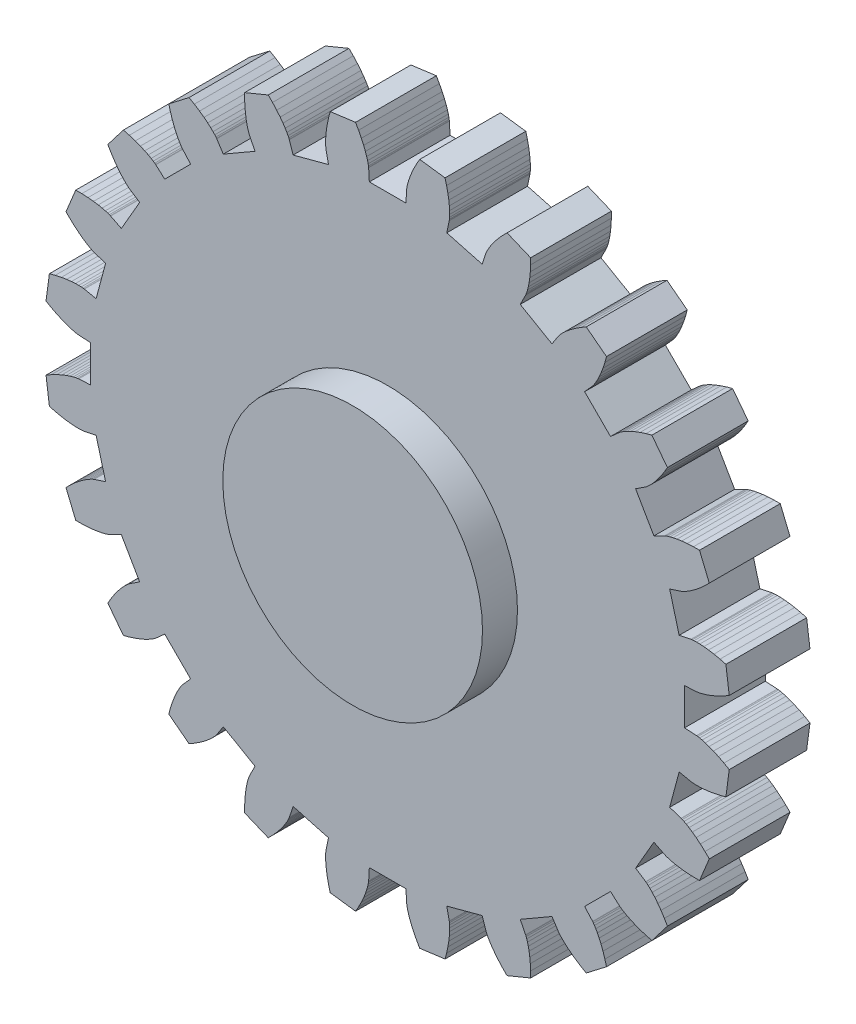
from build123d import *

# Parameters (mm, degrees)
MAIN_GEAR_BODY_DEPTH         = 3
SKETCH2_R                    = 5
CENTRAL_FEATURE_DEPTH        = 1.3
CENTRAL_FEATURE_DEPTH_BACK   = 4.3
SKETCH3_OUTSIDE_W            = 34.792
SKETCH3_OUTSIDE_H            = 34.792
TEETH_CLEARANCE_DEPTH        = 5.3
SKETCH4_R                    = 5
SKETCH4_R_2                  = 4.825
PRINT_CLEARANCE_TOP_DEPTH    = 1.3
SKETCH6_R                    = 5
SKETCH6_R_2                  = 4.825
PRINT_CLEARANCE_BOTTOM_DEPTH = 1.3


with BuildPart() as part:
    # Model → Main Gear Body (new body)
    with BuildSketch(Plane.XY):
        Polygon((11.481280763, -0.655890262), (11.081931867, -0.633076687), (11.081931867, 0.633076687), (11.481280763, 0.655890262), (11.494959484, 0.657119822), (11.535795525, 0.662587053), (11.603342457, 0.674939875), (11.696960474, 0.69678954), (11.81581907, 0.730698092), (11.958900465, 0.779166001), (12.125003794, 0.844620031), (12.312750022, 0.929401369), (12.520587586, 1.035754071), (12.746798737, 1.165813859), (12.614196933, 2.173024562), (12.36203179, 2.240104916), (12.133750013, 2.289041418), (11.930458058, 2.322341602), (11.753073814, 2.342574636), (11.602323381, 2.352358851), (11.478738615, 2.354349128), (11.382655444, 2.351224158), (11.314212973, 2.345673635), (11.273353363, 2.34038543), (11.259822499, 2.338032781), (10.868176499, 2.256709902), (10.540471892, 3.479720146), (10.920308717, 3.605115467), (10.933203113, 3.609843444), (10.971232676, 3.625693529), (11.033280856, 3.655107871), (11.118053808, 3.700443153), (11.224086216, 3.763959167), (11.349747813, 3.847807762), (11.493250558, 3.954022205), (11.652656464, 4.084506989), (11.82588603, 4.24102813), (12.010727273, 4.425203993), (11.621958453, 5.36377495), (11.361023956, 5.363304455), (11.127854994, 5.351489815), (10.922871322, 5.331039494), (10.746294605, 5.304672682), (10.598148527, 5.275106425), (10.478259688, 5.245042794), (10.386259274, 5.21715615), (10.321585504, 5.194080542), (10.28348684, 5.178397283), (10.27102594, 5.172622753), (9.913772864, 4.99270544), (9.280696176, 6.089226427), (9.615135678, 6.30865801), (9.626367017, 6.316562201), (9.658998451, 6.341714983), (9.711319399, 6.386186306), (9.781470148, 6.45191768), (9.867450435, 6.540712645), (9.967128604, 6.654227783), (10.078251291, 6.7939643), (10.198453625, 6.961260207), (10.325269884, 7.157283131), (10.456144594, 7.383023787), (9.837702711, 8.18899294), (9.585781114, 8.121003659), (9.363615046, 8.049243025), (9.170908956, 7.976435853), (9.007173178, 7.905266052), (8.871727365, 7.838364214), (8.76370468, 7.778295462), (8.682056698, 7.727547573), (8.625559041, 7.688519444), (8.592817683, 7.663509918), (8.582275936, 7.654707033), (8.28376199, 7.388456353), (7.388456353, 8.28376199), (7.654707033, 8.582275936), (7.663509918, 8.592817683), (7.688519444, 8.625559041), (7.727547573, 8.682056698), (7.778295462, 8.76370468), (7.838364214, 8.871727365), (7.905266052, 9.007173178), (7.976435853, 9.170908956), (8.049243025, 9.363615046), (8.121003659, 9.585781114), (8.18899294, 9.837702711), (7.383023787, 10.456144594), (7.157283131, 10.325269884), (6.961260207, 10.198453625), (6.7939643, 10.078251291), (6.654227783, 9.967128604), (6.540712645, 9.867450435), (6.45191768, 9.781470148), (6.386186306, 9.711319399), (6.341714983, 9.658998451), (6.316562201, 9.626367017), (6.30865801, 9.615135678), (6.089226427, 9.280696176), (4.99270544, 9.913772864), (5.172622753, 10.27102594), (5.178397283, 10.28348684), (5.194080542, 10.321585504), (5.21715615, 10.386259274), (5.245042794, 10.478259688), (5.275106425, 10.598148527), (5.304672682, 10.746294605), (5.331039494, 10.922871322), (5.351489815, 11.127854994), (5.363304455, 11.361023956), (5.36377495, 11.621958453), (4.425203993, 12.010727273), (4.24102813, 11.82588603), (4.084506989, 11.652656464), (3.954022205, 11.493250558), (3.847807762, 11.349747813), (3.763959167, 11.224086216), (3.700443153, 11.118053808), (3.655107871, 11.033280856), (3.625693529, 10.971232676), (3.609843444, 10.933203113), (3.605115467, 10.920308717), (3.479720146, 10.540471892), (2.256709902, 10.868176499), (2.338032781, 11.259822499), (2.34038543, 11.273353363), (2.345673635, 11.314212973), (2.351224158, 11.382655444), (2.354349128, 11.478738615), (2.352358851, 11.602323381), (2.342574636, 11.753073814), (2.322341602, 11.930458058), (2.289041418, 12.133750013), (2.240104916, 12.36203179), (2.173024562, 12.614196933), (1.165813859, 12.746798737), (1.035754071, 12.520587586), (0.929401369, 12.312750022), (0.844620031, 12.125003794), (0.779166001, 11.958900465), (0.730698092, 11.81581907), (0.69678954, 11.696960474), (0.674939875, 11.603342457), (0.662587053, 11.535795525), (0.657119822, 11.494959484), (0.655890262, 11.481280763), (0.633076687, 11.081931867), (-0.633076687, 11.081931867), (-0.655890262, 11.481280763), (-0.657119822, 11.494959484), (-0.662587053, 11.535795525), (-0.674939875, 11.603342457), (-0.69678954, 11.696960474), (-0.730698092, 11.81581907), (-0.779166001, 11.958900465), (-0.844620031, 12.125003794), (-0.929401369, 12.312750022), (-1.035754071, 12.520587586), (-1.165813859, 12.746798737), (-2.173024562, 12.614196933), (-2.240104916, 12.36203179), (-2.289041418, 12.133750013), (-2.322341602, 11.930458058), (-2.342574636, 11.753073814), (-2.352358851, 11.602323381), (-2.354349128, 11.478738615), (-2.351224158, 11.382655444), (-2.345673635, 11.314212973), (-2.34038543, 11.273353363), (-2.338032781, 11.259822499), (-2.256709902, 10.868176499), (-3.479720146, 10.540471892), (-3.605115467, 10.920308717), (-3.609843444, 10.933203113), (-3.625693529, 10.971232676), (-3.655107871, 11.033280856), (-3.700443153, 11.118053808), (-3.763959167, 11.224086216), (-3.847807762, 11.349747813), (-3.954022205, 11.493250558), (-4.084506989, 11.652656464), (-4.24102813, 11.82588603), (-4.425203993, 12.010727273), (-5.36377495, 11.621958453), (-5.363304455, 11.361023956), (-5.351489815, 11.127854994), (-5.331039494, 10.922871322), (-5.304672682, 10.746294605), (-5.275106425, 10.598148527), (-5.245042794, 10.478259688), (-5.21715615, 10.386259274), (-5.194080542, 10.321585504), (-5.178397283, 10.28348684), (-5.172622753, 10.27102594), (-4.99270544, 9.913772864), (-6.089226427, 9.280696176), (-6.30865801, 9.615135678), (-6.316562201, 9.626367017), (-6.341714983, 9.658998451), (-6.386186306, 9.711319399), (-6.45191768, 9.781470148), (-6.540712645, 9.867450435), (-6.654227783, 9.967128604), (-6.7939643, 10.078251291), (-6.961260207, 10.198453625), (-7.157283131, 10.325269884), (-7.383023787, 10.456144594), (-8.18899294, 9.837702711), (-8.121003659, 9.585781114), (-8.049243025, 9.363615046), (-7.976435853, 9.170908956), (-7.905266052, 9.007173178), (-7.838364214, 8.871727365), (-7.778295462, 8.76370468), (-7.727547573, 8.682056698), (-7.688519444, 8.625559041), (-7.663509918, 8.592817683), (-7.654707033, 8.582275936), (-7.388456353, 8.28376199), (-8.28376199, 7.388456353), (-8.582275936, 7.654707033), (-8.592817683, 7.663509918), (-8.625559041, 7.688519444), (-8.682056698, 7.727547573), (-8.76370468, 7.778295462), (-8.871727365, 7.838364214), (-9.007173178, 7.905266052), (-9.170908956, 7.976435853), (-9.363615046, 8.049243025), (-9.585781114, 8.121003659), (-9.837702711, 8.18899294), (-10.456144594, 7.383023787), (-10.325269884, 7.157283131), (-10.198453625, 6.961260207), (-10.078251291, 6.7939643), (-9.967128604, 6.654227783), (-9.867450435, 6.540712645), (-9.781470148, 6.45191768), (-9.711319399, 6.386186306), (-9.658998451, 6.341714983), (-9.626367017, 6.316562201), (-9.615135678, 6.30865801), (-9.280696176, 6.089226427), (-9.913772864, 4.99270544), (-10.27102594, 5.172622753), (-10.28348684, 5.178397283), (-10.321585504, 5.194080542), (-10.386259274, 5.21715615), (-10.478259688, 5.245042794), (-10.598148527, 5.275106425), (-10.746294605, 5.304672682), (-10.922871322, 5.331039494), (-11.127854994, 5.351489815), (-11.361023956, 5.363304455), (-11.621958453, 5.36377495), (-12.010727273, 4.425203993), (-11.82588603, 4.24102813), (-11.652656464, 4.084506989), (-11.493250558, 3.954022205), (-11.349747813, 3.847807762), (-11.224086216, 3.763959167), (-11.118053808, 3.700443153), (-11.033280856, 3.655107871), (-10.971232676, 3.625693529), (-10.933203113, 3.609843444), (-10.920308717, 3.605115467), (-10.540471892, 3.479720146), (-10.868176499, 2.256709902), (-11.259822499, 2.338032781), (-11.273353363, 2.34038543), (-11.314212973, 2.345673635), (-11.382655444, 2.351224158), (-11.478738615, 2.354349128), (-11.602323381, 2.352358851), (-11.753073814, 2.342574636), (-11.930458058, 2.322341602), (-12.133750014, 2.289041418), (-12.36203179, 2.240104916), (-12.614196933, 2.173024562), (-12.746798737, 1.165813859), (-12.520587586, 1.035754071), (-12.312750022, 0.929401369), (-12.125003794, 0.844620031), (-11.958900465, 0.779166001), (-11.81581907, 0.730698092), (-11.696960474, 0.69678954), (-11.603342457, 0.674939875), (-11.535795525, 0.662587053), (-11.494959484, 0.657119822), (-11.481280763, 0.655890262), (-11.081931867, 0.633076687), (-11.081931867, -0.633076687), (-11.481280763, -0.655890262), (-11.494959484, -0.657119822), (-11.535795525, -0.662587053), (-11.603342457, -0.674939875), (-11.696960474, -0.69678954), (-11.81581907, -0.730698092), (-11.958900465, -0.779166001), (-12.125003794, -0.844620031), (-12.312750022, -0.929401369), (-12.520587586, -1.035754071), (-12.746798737, -1.165813859), (-12.614196933, -2.173024562), (-12.36203179, -2.240104916), (-12.133750014, -2.289041418), (-11.930458058, -2.322341602), (-11.753073814, -2.342574636), (-11.602323381, -2.352358851), (-11.478738615, -2.354349128), (-11.382655444, -2.351224158), (-11.314212973, -2.345673635), (-11.273353363, -2.34038543), (-11.259822499, -2.338032781), (-10.868176499, -2.256709902), (-10.540471892, -3.479720146), (-10.920308717, -3.605115467), (-10.933203113, -3.609843444), (-10.971232676, -3.625693529), (-11.033280856, -3.655107871), (-11.118053808, -3.700443153), (-11.224086216, -3.763959167), (-11.349747813, -3.847807762), (-11.493250558, -3.954022205), (-11.652656464, -4.084506989), (-11.82588603, -4.24102813), (-12.010727273, -4.425203993), (-11.621958453, -5.36377495), (-11.361023956, -5.363304455), (-11.127854994, -5.351489815), (-10.922871322, -5.331039494), (-10.746294605, -5.304672682), (-10.598148527, -5.275106425), (-10.478259688, -5.245042794), (-10.386259274, -5.21715615), (-10.321585504, -5.194080542), (-10.28348684, -5.178397283), (-10.27102594, -5.172622753), (-9.913772864, -4.99270544), (-9.280696176, -6.089226427), (-9.615135678, -6.30865801), (-9.626367017, -6.316562201), (-9.658998451, -6.341714983), (-9.711319399, -6.386186306), (-9.781470148, -6.45191768), (-9.867450435, -6.540712645), (-9.967128604, -6.654227783), (-10.078251291, -6.7939643), (-10.198453625, -6.961260207), (-10.325269884, -7.157283131), (-10.456144594, -7.383023787), (-9.837702711, -8.18899294), (-9.585781114, -8.121003659), (-9.363615046, -8.049243025), (-9.170908956, -7.976435853), (-9.007173178, -7.905266052), (-8.871727365, -7.838364214), (-8.76370468, -7.778295462), (-8.682056698, -7.727547573), (-8.625559041, -7.688519444), (-8.592817683, -7.663509918), (-8.582275936, -7.654707033), (-8.28376199, -7.388456353), (-7.388456353, -8.28376199), (-7.654707033, -8.582275936), (-7.663509918, -8.592817683), (-7.688519444, -8.625559041), (-7.727547573, -8.682056698), (-7.778295462, -8.76370468), (-7.838364214, -8.871727365), (-7.905266052, -9.007173178), (-7.976435853, -9.170908956), (-8.049243025, -9.363615046), (-8.121003659, -9.585781114), (-8.18899294, -9.837702711), (-7.383023787, -10.456144594), (-7.157283131, -10.325269884), (-6.961260207, -10.198453625), (-6.7939643, -10.078251291), (-6.654227783, -9.967128604), (-6.540712645, -9.867450435), (-6.45191768, -9.781470148), (-6.386186306, -9.711319399), (-6.341714983, -9.658998451), (-6.316562201, -9.626367017), (-6.30865801, -9.615135678), (-6.089226427, -9.280696176), (-4.99270544, -9.913772864), (-5.172622753, -10.27102594), (-5.178397283, -10.28348684), (-5.194080542, -10.321585504), (-5.21715615, -10.386259274), (-5.245042794, -10.478259688), (-5.275106425, -10.598148527), (-5.304672682, -10.746294605), (-5.331039494, -10.922871322), (-5.351489815, -11.127854994), (-5.363304455, -11.361023956), (-5.36377495, -11.621958453), (-4.425203993, -12.010727273), (-4.24102813, -11.82588603), (-4.084506989, -11.652656464), (-3.954022205, -11.493250558), (-3.847807762, -11.349747813), (-3.763959167, -11.224086216), (-3.700443153, -11.118053808), (-3.655107871, -11.033280856), (-3.625693529, -10.971232676), (-3.609843444, -10.933203113), (-3.605115467, -10.920308717), (-3.479720146, -10.540471892), (-2.256709902, -10.868176499), (-2.338032781, -11.259822499), (-2.34038543, -11.273353363), (-2.345673635, -11.314212973), (-2.351224158, -11.382655444), (-2.354349128, -11.478738615), (-2.352358851, -11.602323381), (-2.342574636, -11.753073814), (-2.322341602, -11.930458058), (-2.289041418, -12.133750013), (-2.240104916, -12.36203179), (-2.173024562, -12.614196933), (-1.165813859, -12.746798737), (-1.035754071, -12.520587586), (-0.929401369, -12.312750022), (-0.844620031, -12.125003794), (-0.779166001, -11.958900465), (-0.730698092, -11.81581907), (-0.69678954, -11.696960474), (-0.674939875, -11.603342457), (-0.662587053, -11.535795525), (-0.657119822, -11.494959484), (-0.655890262, -11.481280763), (-0.633076687, -11.081931867), (0.633076687, -11.081931867), (0.655890262, -11.481280763), (0.657119822, -11.494959484), (0.662587053, -11.535795525), (0.674939875, -11.603342457), (0.69678954, -11.696960474), (0.730698092, -11.81581907), (0.779166001, -11.958900465), (0.844620031, -12.125003794), (0.929401369, -12.312750022), (1.035754071, -12.520587586), (1.165813859, -12.746798737), (2.173024562, -12.614196933), (2.240104916, -12.36203179), (2.289041418, -12.133750013), (2.322341602, -11.930458058), (2.342574636, -11.753073814), (2.352358851, -11.602323381), (2.354349128, -11.478738615), (2.351224158, -11.382655444), (2.345673635, -11.314212973), (2.34038543, -11.273353363), (2.338032781, -11.259822499), (2.256709902, -10.868176499), (3.479720146, -10.540471892), (3.605115467, -10.920308717), (3.609843444, -10.933203113), (3.625693529, -10.971232676), (3.655107871, -11.033280856), (3.700443153, -11.118053808), (3.763959167, -11.224086216), (3.847807762, -11.349747813), (3.954022205, -11.493250558), (4.084506989, -11.652656464), (4.24102813, -11.82588603), (4.425203993, -12.010727273), (5.36377495, -11.621958453), (5.363304455, -11.361023956), (5.351489815, -11.127854994), (5.331039494, -10.922871322), (5.304672682, -10.746294605), (5.275106425, -10.598148527), (5.245042794, -10.478259688), (5.21715615, -10.386259274), (5.194080542, -10.321585504), (5.178397283, -10.28348684), (5.172622753, -10.27102594), (4.99270544, -9.913772864), (6.089226427, -9.280696176), (6.30865801, -9.615135678), (6.316562201, -9.626367017), (6.341714983, -9.658998451), (6.386186306, -9.711319399), (6.45191768, -9.781470148), (6.540712645, -9.867450435), (6.654227783, -9.967128604), (6.7939643, -10.078251291), (6.961260207, -10.198453625), (7.157283131, -10.325269884), (7.383023787, -10.456144594), (8.18899294, -9.837702711), (8.121003659, -9.585781114), (8.049243025, -9.363615046), (7.976435853, -9.170908956), (7.905266052, -9.007173178), (7.838364214, -8.871727365), (7.778295462, -8.76370468), (7.727547573, -8.682056698), (7.688519444, -8.625559041), (7.663509918, -8.592817683), (7.654707033, -8.582275936), (7.388456353, -8.28376199), (8.28376199, -7.388456353), (8.582275936, -7.654707033), (8.592817683, -7.663509918), (8.625559041, -7.688519444), (8.682056698, -7.727547573), (8.76370468, -7.778295462), (8.871727365, -7.838364214), (9.007173178, -7.905266052), (9.170908956, -7.976435853), (9.363615046, -8.049243025), (9.585781114, -8.121003659), (9.837702711, -8.18899294), (10.456144594, -7.383023787), (10.325269884, -7.157283131), (10.198453625, -6.961260207), (10.078251291, -6.7939643), (9.967128604, -6.654227783), (9.867450435, -6.540712645), (9.781470148, -6.45191768), (9.711319399, -6.386186306), (9.658998451, -6.341714983), (9.626367017, -6.316562201), (9.615135678, -6.30865801), (9.280696176, -6.089226427), (9.913772864, -4.99270544), (10.27102594, -5.172622753), (10.28348684, -5.178397283), (10.321585504, -5.194080542), (10.386259274, -5.21715615), (10.478259688, -5.245042794), (10.598148527, -5.275106425), (10.746294605, -5.304672682), (10.922871322, -5.331039494), (11.127854994, -5.351489815), (11.361023956, -5.363304455), (11.621958453, -5.36377495), (12.010727273, -4.425203993), (11.82588603, -4.24102813), (11.652656464, -4.084506989), (11.493250558, -3.954022205), (11.349747813, -3.847807762), (11.224086216, -3.763959167), (11.118053808, -3.700443153), (11.033280856, -3.655107871), (10.971232676, -3.625693529), (10.933203113, -3.609843444), (10.920308717, -3.605115467), (10.540471892, -3.479720146), (10.868176499, -2.256709902), (11.259822499, -2.338032781), (11.273353363, -2.34038543), (11.314212973, -2.345673635), (11.382655444, -2.351224158), (11.478738615, -2.354349128), (11.602323381, -2.352358851), (11.753073814, -2.342574636), (11.930458058, -2.322341602), (12.133750013, -2.289041418), (12.36203179, -2.240104916), (12.614196933, -2.173024562), (12.746798737, -1.165813859), (12.520587586, -1.035754071), (12.312750022, -0.929401369), (12.125003794, -0.844620031), (11.958900465, -0.779166001), (11.81581907, -0.730698092), (11.696960474, -0.69678954), (11.603342457, -0.674939875), (11.535795525, -0.662587053), (11.494959484, -0.657119822), align=None)
    extrude(amount=MAIN_GEAR_BODY_DEPTH)

    # Sketch2 → Central Feature (add, two sides)
    with BuildSketch(Plane.XY.offset(3)) as central_feature_sk:
        Circle(SKETCH2_R)
    extrude(amount=CENTRAL_FEATURE_DEPTH)
    extrude(central_feature_sk.sketch, amount=-CENTRAL_FEATURE_DEPTH_BACK)

    # Sketch3 outside → Teeth Clearance (cut, through all)
    with BuildSketch(Plane(origin=(0, 0, 0), x_dir=(-1, 0, 0), z_dir=(0, 0, -1))):
        Rectangle(SKETCH3_OUTSIDE_W, SKETCH3_OUTSIDE_H)
        Polygon((-11.477615752, -0.705762411), (-11.489401209, -0.706821789), (-11.527976246, -0.711986312), (-11.59315705, -0.723906422), (-11.684412493, -0.745204681), (-11.800930862, -0.778445602), (-11.941703887, -0.826131565), (-12.105537815, -0.890691324), (-12.291059816, -0.974468259), (-12.496724072, -1.079708856), (-12.692857237, -1.192475348), (-12.568993946, -2.133310454), (-12.35035774, -2.191471522), (-12.124463053, -2.239896306), (-11.923579494, -2.272801984), (-11.748618777, -2.292758582), (-11.600300442, -2.302384946), (-11.479148956, -2.304336036), (-11.385490572, -2.301289929), (-11.319445598, -2.295933837), (-11.280848297, -2.290938429), (-11.269190232, -2.288911409), (-10.832102983, -2.198152934), (-10.479952826, -3.512395209), (-10.903860726, -3.652339689), (-10.914970416, -3.656413271), (-10.950894363, -3.67138577), (-11.010769034, -3.699769746), (-11.093402628, -3.743960931), (-11.197347347, -3.806226368), (-11.320981611, -3.888722212), (-11.462523738, -3.993485491), (-11.620041165, -4.122424424), (-11.79145931, -4.27730886), (-11.951723284, -4.436995926), (-11.588574488, -5.313714674), (-11.362334938, -5.313306738), (-11.13160417, -5.30161564), (-10.929048936, -5.281407594), (-10.754884713, -5.255401021), (-10.609128716, -5.226311764), (-10.491600388, -5.196840061), (-10.401921726, -5.169657174), (-10.339513439, -5.14738989), (-10.303524216, -5.132574979), (-10.292788022, -5.127599699), (-9.894084181, -4.926807239), (-9.213782319, -6.105124628), (-9.58702561, -6.350016053), (-9.596702427, -6.35682623), (-9.627527127, -6.380586356), (-9.678015304, -6.423499876), (-9.746395706, -6.487572431), (-9.830683114, -6.574619098), (-9.928753148, -6.686302866), (-10.038357612, -6.824130221), (-10.157135911, -6.989444176), (-10.282626082, -7.183417334), (-10.39609914, -7.379142564), (-9.81841283, -8.13199802), (-9.599987788, -8.07304888), (-9.380144858, -8.00203863), (-9.189721754, -7.930094003), (-9.028223029, -7.859896565), (-8.894962401, -7.794074073), (-8.789066591, -7.735188024), (-8.709479105, -7.685720826), (-8.654960526, -7.648059828), (-8.624031987, -7.624435026), (-8.614949317, -7.616850543), (-8.281799893, -7.319707773), (-7.319707773, -8.281799893), (-7.616850543, -8.614949317), (-7.624435026, -8.624031987), (-7.648059828, -8.654960526), (-7.685720826, -8.709479105), (-7.735188024, -8.789066591), (-7.794074073, -8.894962401), (-7.859896565, -9.028223029), (-7.930094003, -9.189721754), (-8.00203863, -9.380144858), (-8.07304888, -9.599987788), (-8.13199802, -9.81841283), (-7.379142564, -10.39609914), (-7.183417334, -10.282626082), (-6.989444176, -10.157135911), (-6.824130221, -10.038357612), (-6.686302866, -9.928753148), (-6.574619098, -9.830683114), (-6.487572431, -9.746395706), (-6.423499876, -9.678015304), (-6.380586356, -9.627527127), (-6.35682623, -9.596702427), (-6.350016053, -9.58702561), (-6.105124628, -9.213782319), (-4.926807239, -9.894084181), (-5.127599699, -10.292788022), (-5.132574979, -10.303524216), (-5.14738989, -10.339513439), (-5.169657174, -10.401921726), (-5.196840061, -10.491600388), (-5.226311764, -10.609128716), (-5.255401021, -10.754884713), (-5.281407594, -10.929048936), (-5.30161564, -11.13160417), (-5.313306738, -11.362334938), (-5.313714674, -11.588574488), (-4.436995926, -11.951723284), (-4.27730886, -11.79145931), (-4.122424424, -11.620041165), (-3.993485491, -11.462523738), (-3.888722212, -11.320981611), (-3.806226368, -11.197347347), (-3.743960931, -11.093402628), (-3.699769746, -11.010769034), (-3.67138577, -10.950894363), (-3.656413271, -10.914970416), (-3.652339689, -10.903860726), (-3.512395209, -10.479952826), (-2.198152934, -10.832102983), (-2.288911409, -11.269190232), (-2.290938429, -11.280848297), (-2.295933837, -11.319445598), (-2.301289929, -11.385490572), (-2.304336036, -11.479148956), (-2.302384946, -11.600300442), (-2.292758582, -11.748618777), (-2.272801984, -11.923579494), (-2.239896306, -12.124463053), (-2.191471522, -12.35035774), (-2.133310454, -12.568993946), (-1.192475348, -12.692857237), (-1.079708856, -12.496724072), (-0.974468259, -12.291059816), (-0.890691324, -12.105537815), (-0.826131565, -11.941703887), (-0.778445602, -11.800930862), (-0.745204681, -11.684412493), (-0.723906422, -11.59315705), (-0.711986312, -11.527976246), (-0.706821789, -11.489401209), (-0.705762411, -11.477615752), (-0.680301862, -11.031931867), (0.680301862, -11.031931867), (0.705762411, -11.477615752), (0.706821789, -11.489401209), (0.711986312, -11.527976246), (0.723906422, -11.59315705), (0.745204681, -11.684412493), (0.778445602, -11.800930862), (0.826131565, -11.941703887), (0.890691324, -12.105537815), (0.974468259, -12.291059816), (1.079708856, -12.496724072), (1.192475348, -12.692857237), (2.133310454, -12.568993946), (2.191471522, -12.35035774), (2.239896306, -12.124463053), (2.272801984, -11.923579494), (2.292758582, -11.748618777), (2.302384946, -11.600300442), (2.304336036, -11.479148956), (2.301289929, -11.385490572), (2.295933837, -11.319445598), (2.290938429, -11.280848297), (2.288911409, -11.269190232), (2.198152934, -10.832102983), (3.512395209, -10.479952826), (3.652339689, -10.903860726), (3.656413271, -10.914970416), (3.67138577, -10.950894363), (3.699769746, -11.010769034), (3.743960931, -11.093402628), (3.806226368, -11.197347347), (3.888722212, -11.320981611), (3.993485491, -11.462523738), (4.122424424, -11.620041165), (4.27730886, -11.79145931), (4.436995926, -11.951723284), (5.313714674, -11.588574488), (5.313306738, -11.362334938), (5.30161564, -11.13160417), (5.281407594, -10.929048936), (5.255401021, -10.754884713), (5.226311764, -10.609128716), (5.196840061, -10.491600388), (5.169657174, -10.401921726), (5.14738989, -10.339513439), (5.132574979, -10.303524216), (5.127599699, -10.292788022), (4.926807239, -9.894084181), (6.105124628, -9.213782319), (6.350016053, -9.58702561), (6.35682623, -9.596702427), (6.380586356, -9.627527127), (6.423499876, -9.678015304), (6.487572431, -9.746395706), (6.574619098, -9.830683114), (6.686302866, -9.928753148), (6.824130221, -10.038357612), (6.989444176, -10.157135911), (7.183417334, -10.282626082), (7.379142564, -10.39609914), (8.13199802, -9.81841283), (8.07304888, -9.599987788), (8.00203863, -9.380144858), (7.930094003, -9.189721754), (7.859896565, -9.028223029), (7.794074073, -8.894962401), (7.735188024, -8.789066591), (7.685720826, -8.709479105), (7.648059828, -8.654960526), (7.624435026, -8.624031987), (7.616850543, -8.614949317), (7.319707773, -8.281799893), (8.281799893, -7.319707773), (8.614949317, -7.616850543), (8.624031987, -7.624435026), (8.654960526, -7.648059828), (8.709479105, -7.685720826), (8.789066591, -7.735188024), (8.894962401, -7.794074073), (9.028223029, -7.859896565), (9.189721754, -7.930094003), (9.380144858, -8.00203863), (9.599987788, -8.07304888), (9.81841283, -8.13199802), (10.39609914, -7.379142564), (10.282626082, -7.183417334), (10.157135911, -6.989444176), (10.038357612, -6.824130221), (9.928753148, -6.686302866), (9.830683114, -6.574619098), (9.746395706, -6.487572431), (9.678015304, -6.423499876), (9.627527127, -6.380586356), (9.596702427, -6.35682623), (9.58702561, -6.350016053), (9.213782319, -6.105124628), (9.894084181, -4.926807239), (10.292788022, -5.127599699), (10.303524216, -5.132574979), (10.339513439, -5.14738989), (10.401921726, -5.169657174), (10.491600388, -5.196840061), (10.609128716, -5.226311764), (10.754884713, -5.255401021), (10.929048936, -5.281407594), (11.13160417, -5.30161564), (11.362334938, -5.313306738), (11.588574488, -5.313714674), (11.951723284, -4.436995926), (11.79145931, -4.27730886), (11.620041165, -4.122424424), (11.462523738, -3.993485491), (11.320981611, -3.888722212), (11.197347347, -3.806226368), (11.093402628, -3.743960931), (11.010769034, -3.699769746), (10.950894363, -3.67138577), (10.914970416, -3.656413271), (10.903860726, -3.652339689), (10.479952826, -3.512395209), (10.832102983, -2.198152934), (11.269190232, -2.288911409), (11.280848297, -2.290938429), (11.319445598, -2.295933837), (11.385490572, -2.301289929), (11.479148956, -2.304336036), (11.600300442, -2.302384946), (11.748618777, -2.292758582), (11.923579494, -2.272801984), (12.124463053, -2.239896306), (12.35035774, -2.191471522), (12.568993946, -2.133310454), (12.692857237, -1.192475348), (12.496724072, -1.079708856), (12.291059816, -0.974468259), (12.105537815, -0.890691324), (11.941703887, -0.826131565), (11.800930862, -0.778445602), (11.684412493, -0.745204681), (11.59315705, -0.723906422), (11.527976246, -0.711986312), (11.489401209, -0.706821789), (11.477615752, -0.705762411), (11.031931867, -0.680301862), (11.031931867, 0.680301862), (11.477615752, 0.705762411), (11.489401209, 0.706821789), (11.527976246, 0.711986312), (11.59315705, 0.723906422), (11.684412493, 0.745204681), (11.800930862, 0.778445602), (11.941703887, 0.826131565), (12.105537815, 0.890691324), (12.291059816, 0.974468259), (12.496724072, 1.079708856), (12.692857237, 1.192475348), (12.568993946, 2.133310454), (12.35035774, 2.191471522), (12.124463053, 2.239896306), (11.923579494, 2.272801984), (11.748618777, 2.292758582), (11.600300442, 2.302384946), (11.479148956, 2.304336036), (11.385490572, 2.301289929), (11.319445598, 2.295933837), (11.280848297, 2.290938429), (11.269190232, 2.288911409), (10.832102983, 2.198152934), (10.479952826, 3.512395209), (10.903860726, 3.652339689), (10.914970416, 3.656413271), (10.950894363, 3.67138577), (11.010769034, 3.699769746), (11.093402628, 3.743960931), (11.197347347, 3.806226368), (11.320981611, 3.888722212), (11.462523738, 3.993485491), (11.620041165, 4.122424424), (11.79145931, 4.27730886), (11.951723284, 4.436995926), (11.588574488, 5.313714674), (11.362334938, 5.313306738), (11.13160417, 5.30161564), (10.929048936, 5.281407594), (10.754884713, 5.255401021), (10.609128716, 5.226311764), (10.491600388, 5.196840061), (10.401921726, 5.169657174), (10.339513439, 5.14738989), (10.303524216, 5.132574979), (10.292788022, 5.127599699), (9.894084181, 4.926807239), (9.213782319, 6.105124628), (9.58702561, 6.350016053), (9.596702427, 6.35682623), (9.627527127, 6.380586356), (9.678015304, 6.423499876), (9.746395706, 6.487572431), (9.830683114, 6.574619098), (9.928753148, 6.686302866), (10.038357612, 6.824130221), (10.157135911, 6.989444176), (10.282626082, 7.183417334), (10.39609914, 7.379142564), (9.81841283, 8.13199802), (9.599987788, 8.07304888), (9.380144858, 8.00203863), (9.189721754, 7.930094003), (9.028223029, 7.859896565), (8.894962401, 7.794074073), (8.789066591, 7.735188024), (8.709479105, 7.685720826), (8.654960526, 7.648059828), (8.624031987, 7.624435026), (8.614949317, 7.616850543), (8.281799893, 7.319707773), (7.319707773, 8.281799893), (7.616850543, 8.614949317), (7.624435026, 8.624031987), (7.648059828, 8.654960526), (7.685720826, 8.709479105), (7.735188024, 8.789066591), (7.794074073, 8.894962401), (7.859896565, 9.028223029), (7.930094003, 9.189721754), (8.00203863, 9.380144858), (8.07304888, 9.599987788), (8.13199802, 9.81841283), (7.379142564, 10.39609914), (7.183417334, 10.282626082), (6.989444176, 10.157135911), (6.824130221, 10.038357612), (6.686302866, 9.928753148), (6.574619098, 9.830683114), (6.487572431, 9.746395706), (6.423499876, 9.678015304), (6.380586356, 9.627527127), (6.35682623, 9.596702427), (6.350016053, 9.58702561), (6.105124628, 9.213782319), (4.926807239, 9.894084181), (5.127599699, 10.292788022), (5.132574979, 10.303524216), (5.14738989, 10.339513439), (5.169657174, 10.401921726), (5.196840061, 10.491600388), (5.226311764, 10.609128716), (5.255401021, 10.754884713), (5.281407594, 10.929048936), (5.30161564, 11.13160417), (5.313306738, 11.362334938), (5.313714674, 11.588574488), (4.436995926, 11.951723284), (4.27730886, 11.79145931), (4.122424424, 11.620041165), (3.993485491, 11.462523738), (3.888722212, 11.320981611), (3.806226368, 11.197347347), (3.743960931, 11.093402628), (3.699769746, 11.010769034), (3.67138577, 10.950894363), (3.656413271, 10.914970416), (3.652339689, 10.903860726), (3.512395209, 10.479952826), (2.198152934, 10.832102983), (2.288911409, 11.269190232), (2.290938429, 11.280848297), (2.295933837, 11.319445598), (2.301289929, 11.385490572), (2.304336036, 11.479148956), (2.302384946, 11.600300442), (2.292758582, 11.748618777), (2.272801984, 11.923579494), (2.239896306, 12.124463053), (2.191471522, 12.35035774), (2.133310454, 12.568993946), (1.192475348, 12.692857237), (1.079708856, 12.496724072), (0.974468259, 12.291059816), (0.890691324, 12.105537815), (0.826131565, 11.941703887), (0.778445602, 11.800930862), (0.745204681, 11.684412493), (0.723906422, 11.59315705), (0.711986312, 11.527976246), (0.706821789, 11.489401209), (0.705762411, 11.477615752), (0.680301862, 11.031931867), (-0.680301862, 11.031931867), (-0.705762411, 11.477615752), (-0.706821789, 11.489401209), (-0.711986312, 11.527976246), (-0.723906422, 11.59315705), (-0.745204681, 11.684412493), (-0.778445602, 11.800930862), (-0.826131565, 11.941703887), (-0.890691324, 12.105537815), (-0.974468259, 12.291059816), (-1.079708856, 12.496724072), (-1.192475348, 12.692857237), (-2.133310454, 12.568993946), (-2.191471522, 12.35035774), (-2.239896306, 12.124463053), (-2.272801984, 11.923579494), (-2.292758582, 11.748618777), (-2.302384946, 11.600300442), (-2.304336036, 11.479148956), (-2.301289929, 11.385490572), (-2.295933837, 11.319445598), (-2.290938429, 11.280848297), (-2.288911409, 11.269190232), (-2.198152934, 10.832102983), (-3.512395209, 10.479952826), (-3.652339689, 10.903860726), (-3.656413271, 10.914970416), (-3.67138577, 10.950894363), (-3.699769746, 11.010769034), (-3.743960931, 11.093402628), (-3.806226368, 11.197347347), (-3.888722212, 11.320981611), (-3.993485491, 11.462523738), (-4.122424424, 11.620041165), (-4.27730886, 11.79145931), (-4.436995926, 11.951723284), (-5.313714674, 11.588574488), (-5.313306738, 11.362334938), (-5.30161564, 11.13160417), (-5.281407594, 10.929048936), (-5.255401021, 10.754884713), (-5.226311764, 10.609128716), (-5.196840061, 10.491600388), (-5.169657174, 10.401921726), (-5.14738989, 10.339513439), (-5.132574979, 10.303524216), (-5.127599699, 10.292788022), (-4.926807239, 9.894084181), (-6.105124628, 9.213782319), (-6.350016053, 9.58702561), (-6.35682623, 9.596702427), (-6.380586356, 9.627527127), (-6.423499876, 9.678015304), (-6.487572431, 9.746395706), (-6.574619098, 9.830683114), (-6.686302866, 9.928753148), (-6.824130221, 10.038357612), (-6.989444176, 10.157135911), (-7.183417334, 10.282626082), (-7.379142564, 10.39609914), (-8.13199802, 9.81841283), (-8.07304888, 9.599987788), (-8.00203863, 9.380144858), (-7.930094003, 9.189721754), (-7.859896565, 9.028223029), (-7.794074073, 8.894962401), (-7.735188024, 8.789066591), (-7.685720826, 8.709479105), (-7.648059828, 8.654960526), (-7.624435026, 8.624031987), (-7.616850543, 8.614949317), (-7.319707773, 8.281799893), (-8.281799893, 7.319707773), (-8.614949317, 7.616850543), (-8.624031987, 7.624435026), (-8.654960526, 7.648059828), (-8.709479105, 7.685720826), (-8.789066591, 7.735188024), (-8.894962401, 7.794074073), (-9.028223029, 7.859896565), (-9.189721754, 7.930094003), (-9.380144858, 8.00203863), (-9.599987788, 8.07304888), (-9.81841283, 8.13199802), (-10.39609914, 7.379142564), (-10.282626082, 7.183417334), (-10.157135911, 6.989444176), (-10.038357612, 6.824130221), (-9.928753148, 6.686302866), (-9.830683114, 6.574619098), (-9.746395706, 6.487572431), (-9.678015304, 6.423499876), (-9.627527127, 6.380586356), (-9.596702427, 6.35682623), (-9.58702561, 6.350016053), (-9.213782319, 6.105124628), (-9.894084181, 4.926807239), (-10.292788022, 5.127599699), (-10.303524216, 5.132574979), (-10.339513439, 5.14738989), (-10.401921726, 5.169657174), (-10.491600388, 5.196840061), (-10.609128716, 5.226311764), (-10.754884713, 5.255401021), (-10.929048936, 5.281407594), (-11.13160417, 5.30161564), (-11.362334938, 5.313306738), (-11.588574488, 5.313714674), (-11.951723284, 4.436995926), (-11.79145931, 4.27730886), (-11.620041165, 4.122424424), (-11.462523738, 3.993485491), (-11.320981611, 3.888722212), (-11.197347347, 3.806226368), (-11.093402628, 3.743960931), (-11.010769034, 3.699769746), (-10.950894363, 3.67138577), (-10.914970416, 3.656413271), (-10.903860726, 3.652339689), (-10.479952826, 3.512395209), (-10.832102983, 2.198152934), (-11.269190232, 2.288911409), (-11.280848297, 2.290938429), (-11.319445598, 2.295933837), (-11.385490572, 2.301289929), (-11.479148956, 2.304336036), (-11.600300442, 2.302384946), (-11.748618777, 2.292758582), (-11.923579494, 2.272801984), (-12.124463053, 2.239896306), (-12.35035774, 2.191471522), (-12.568993946, 2.133310454), (-12.692857237, 1.192475348), (-12.496724072, 1.079708856), (-12.291059816, 0.974468259), (-12.105537815, 0.890691324), (-11.941703887, 0.826131565), (-11.800930862, 0.778445602), (-11.684412493, 0.745204681), (-11.59315705, 0.723906422), (-11.527976246, 0.711986312), (-11.489401209, 0.706821789), (-11.477615752, 0.705762411), (-11.031931867, 0.680301862), (-11.031931867, -0.680301862), align=None, mode=Mode.SUBTRACT)
    extrude(amount=-TEETH_CLEARANCE_DEPTH, mode=Mode.SUBTRACT)

    # Sketch4 → Print Clearance - Top (cut)
    with BuildSketch(Plane(origin=(0, 0, -1.3), x_dir=(-1, 0, 0), z_dir=(0, 0, -1))):
        Circle(SKETCH4_R)
        Circle(SKETCH4_R_2, mode=Mode.SUBTRACT)
    extrude(amount=-PRINT_CLEARANCE_TOP_DEPTH, mode=Mode.SUBTRACT)

    # Sketch6 → Print Clearance - Bottom (cut)
    with BuildSketch(Plane.XY.offset(4.3)):
        Circle(SKETCH6_R)
        Circle(SKETCH6_R_2, mode=Mode.SUBTRACT)
    extrude(amount=-PRINT_CLEARANCE_BOTTOM_DEPTH, mode=Mode.SUBTRACT)


solid = part.part
